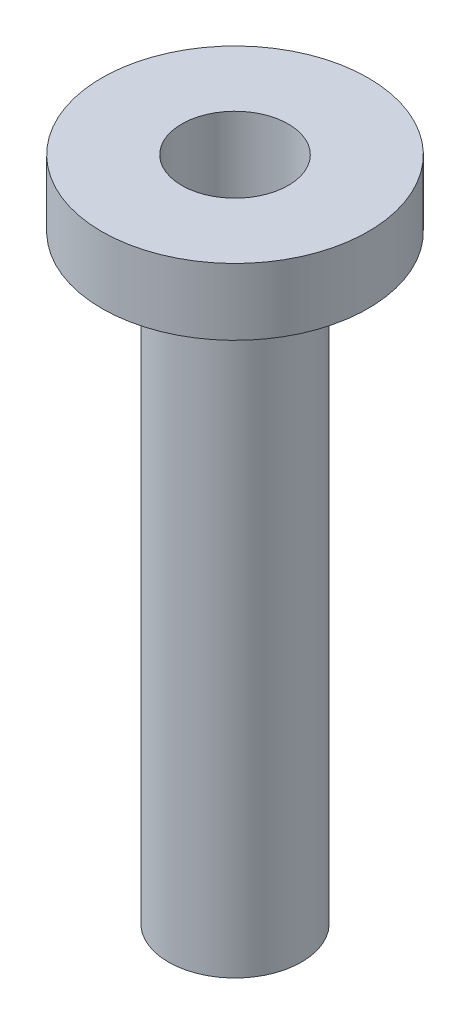
from build123d import *


with BuildPart() as part:
    # Sketch1 → Revolve1 (revolve)
    with BuildSketch(Plane.XY):
        Polygon((-5.08, 0), (-12.7, 0), (-12.7, -6.35), (-11.1125, -6.35), (-11.1125, -4.318), (-8.0645, -4.318), (-8.0645, -6.35), (-6.35, -6.35), (-6.35, -63.5), (-5.08, -62.23), align=None)
    revolve(axis=Axis((0, 0, 0), (0, -1, 0)))


solid = part.part
